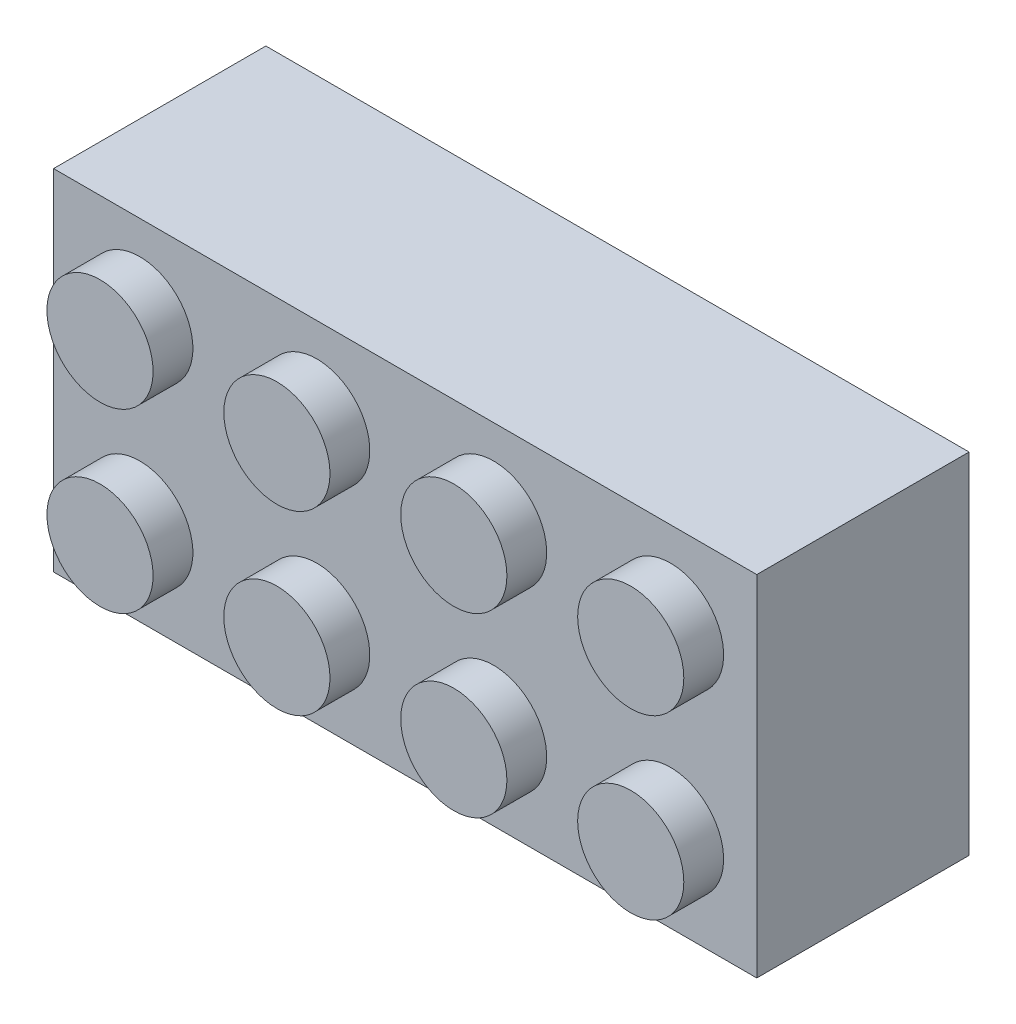
from build123d import *

# Parameters (mm, degrees)
SKETCH1_W           = 31.8
SKETCH1_H           = 15.8
BOSS_EXTRUDE1_DEPTH = 9.6
SKETCH2_R           = 2.4
BOSS_EXTRUDE2_DEPTH = 1.8
CUT_EXTRUDE3_DEPTH  = 8.6
SKETCH7_R           = 1.3
CUT_EXTRUDE4_DEPTH  = 1.7
SKETCH8_R           = 3.25
SKETCH8_R_2         = 2.05
BOSS_EXTRUDE4_DEPTH = 8.6
BOSS_EXTRUDE5_DEPTH = 6.3


with BuildPart() as part:
    # Sketch1 → Boss-Extrude1 (new body)
    with BuildSketch(Plane.XY):
        Rectangle(SKETCH1_W, SKETCH1_H)
    extrude(amount=BOSS_EXTRUDE1_DEPTH)

    # Sketch2 → Boss-Extrude2 (add)
    with BuildSketch(Plane.XY.offset(9.6)):
        with Locations((-12, 4)):
            Circle(SKETCH2_R)
        with Locations((-4, 4)):
            Circle(SKETCH2_R)
        with Locations((4, 4)):
            Circle(SKETCH2_R)
        with Locations((12, 4)):
            Circle(SKETCH2_R)
        with Locations((-4, -4)):
            Circle(SKETCH2_R)
        with Locations((4, -4)):
            Circle(SKETCH2_R)
        with Locations((12, -4)):
            Circle(SKETCH2_R)
        with Locations((-12, -4)):
            Circle(SKETCH2_R)
    extrude(amount=BOSS_EXTRUDE2_DEPTH)

    # Sketch6 → Cut-Extrude3 (cut)
    with BuildSketch(Plane(origin=(0, 0, 0), x_dir=(-1, 0, 0), z_dir=(0, 0, -1))):
        Polygon((-14.7, -4.6), (-14.7, -6.7), (-12.6, -6.7), (-12.6, -6.5), (-11.4, -6.5), (-11.4, -6.7), (-4.6, -6.7), (-4.6, -6.5), (-3.4, -6.5), (-3.4, -6.7), (3.4, -6.7), (3.4, -6.5), (4.6, -6.5), (4.6, -6.7), (11.4, -6.7), (11.4, -6.5), (12.6, -6.5), (12.6, -6.7), (14.7, -6.7), (14.7, -4.6), (14.5, -4.6), (14.5, -3.4), (14.7, -3.4), (14.7, 3.4), (14.5, 3.4), (14.5, 4.6), (14.7, 4.6), (14.7, 6.7), (12.6, 6.7), (12.6, 6.5), (11.4, 6.5), (11.4, 6.7), (4.6, 6.7), (4.6, 6.5), (3.4, 6.5), (3.4, 6.7), (-3.4, 6.7), (-3.4, 6.5), (-4.6, 6.5), (-4.6, 6.7), (-11.4, 6.7), (-11.4, 6.5), (-12.6, 6.5), (-12.6, 6.7), (-14.7, 6.7), (-14.7, 4.6), (-14.5, 4.6), (-14.5, 3.4), (-14.7, 3.4), (-14.7, -3.4), (-14.5, -3.4), (-14.5, -4.6), align=None)
    extrude(amount=-CUT_EXTRUDE3_DEPTH, mode=Mode.SUBTRACT)

    # Sketch7 → Cut-Extrude4 (cut)
    with BuildSketch(Plane(origin=(0, 0, 8.6), x_dir=(-1, 0, 0), z_dir=(0, 0, -1))):
        with Locations((-12, 4)):
            Circle(SKETCH7_R)
        with Locations((-4, 4)):
            Circle(SKETCH7_R)
        with Locations((4, 4)):
            Circle(SKETCH7_R)
        with Locations((12, 4)):
            Circle(SKETCH7_R)
        with Locations((-4, -4)):
            Circle(SKETCH7_R)
        with Locations((4, -4)):
            Circle(SKETCH7_R)
        with Locations((12, -4)):
            Circle(SKETCH7_R)
        with Locations((-12, -4)):
            Circle(SKETCH7_R)
    extrude(amount=-CUT_EXTRUDE4_DEPTH, mode=Mode.SUBTRACT)

    # Sketch8 → Boss-Extrude4 (add)
    with BuildSketch(Plane(origin=(0, 0, 8.6), x_dir=(-1, 0, 0), z_dir=(0, 0, -1))):
        with Locations((-8, 0)):
            Circle(SKETCH8_R)
        with Locations((-8, 0)):
            Circle(SKETCH8_R_2, mode=Mode.SUBTRACT)
        Circle(SKETCH8_R)
        Circle(SKETCH8_R_2, mode=Mode.SUBTRACT)
        with Locations((8, 0)):
            Circle(SKETCH8_R)
        with Locations((8, 0)):
            Circle(SKETCH8_R_2, mode=Mode.SUBTRACT)
    extrude(amount=BOSS_EXTRUDE4_DEPTH)

    # Sketch9 → Boss-Extrude5 (add)
    with BuildSketch(Plane(origin=(0, 0, 8.6), x_dir=(-1, 0, 0), z_dir=(0, 0, -1))):
        with BuildLine():
            ThreePointArc((0.55, 3.203123476), (0, 3.25), (-0.55, 3.203123476))
            Line((-0.55, 3.203123476), (-0.55, 6.7))
            Line((-0.55, 6.7), (0.55, 6.7))
            Line((0.55, 6.7), (0.55, 3.203123476))
        make_face()
        with BuildLine():
            ThreePointArc((-0.55, -3.203123476), (0, -3.25), (0.55, -3.203123476))
            Line((0.55, -3.203123476), (0.55, -6.7))
            Line((0.55, -6.7), (-0.55, -6.7))
            Line((-0.55, -6.7), (-0.55, -3.203123476))
        make_face()
    extrude(amount=BOSS_EXTRUDE5_DEPTH)


solid = part.part
